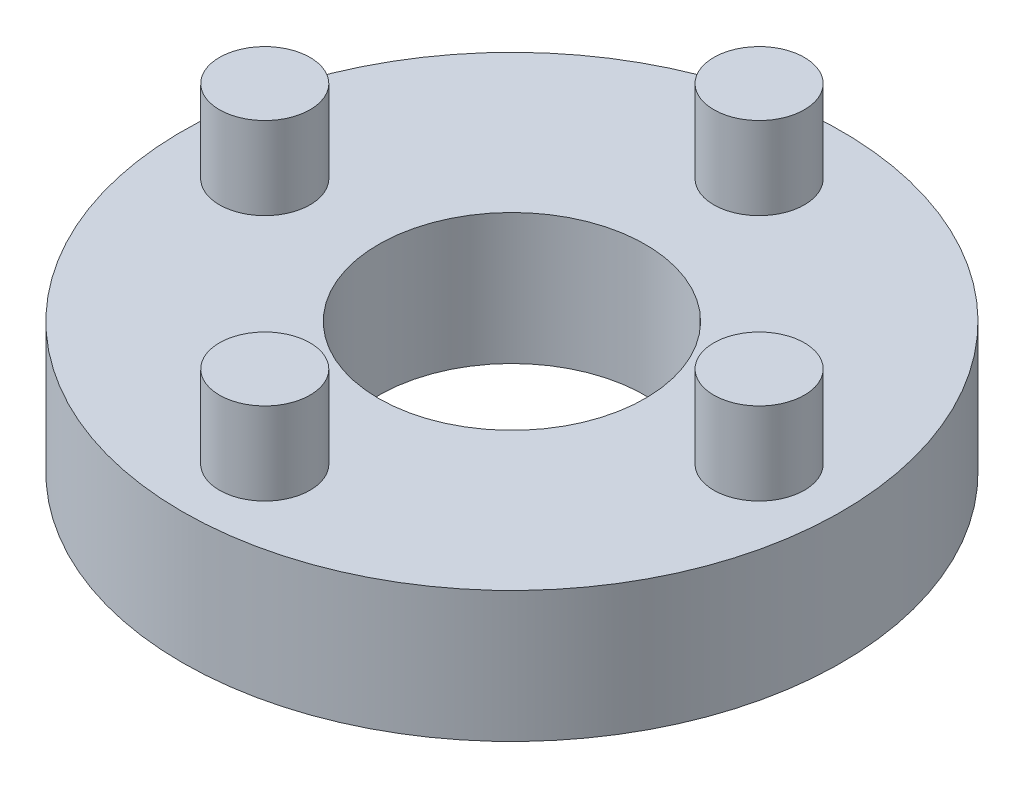
from build123d import *

# Parameters (mm, degrees)
SKETCH1_R           = 8
SKETCH1_R_2         = 3.2385
BOSS_EXTRUDE1_DEPTH = 3.175
SKETCH2_R           = 1.1
BOSS_EXTRUDE2_DEPTH = 2


with BuildPart() as part:
    # Sketch1 → Boss-Extrude1 (new body)
    with BuildSketch(Plane(origin=(0, 0, 0), x_dir=(1, 0, 0), z_dir=(0, 1, 0))):
        Circle(SKETCH1_R)
        Circle(SKETCH1_R_2, mode=Mode.SUBTRACT)
    extrude(amount=BOSS_EXTRUDE1_DEPTH)

    # Sketch2 → Boss-Extrude2 (add)
    with BuildSketch(Plane(origin=(0, 3.175, 0), x_dir=(1, 0, 0), z_dir=(0, 1, 0))):
        with Locations((0, 6)):
            Circle(SKETCH2_R)
        with Locations((6, 0)):
            Circle(SKETCH2_R)
        with Locations((0, -6)):
            Circle(SKETCH2_R)
        with Locations((-6, 0)):
            Circle(SKETCH2_R)
    extrude(amount=BOSS_EXTRUDE2_DEPTH)


solid = part.part
